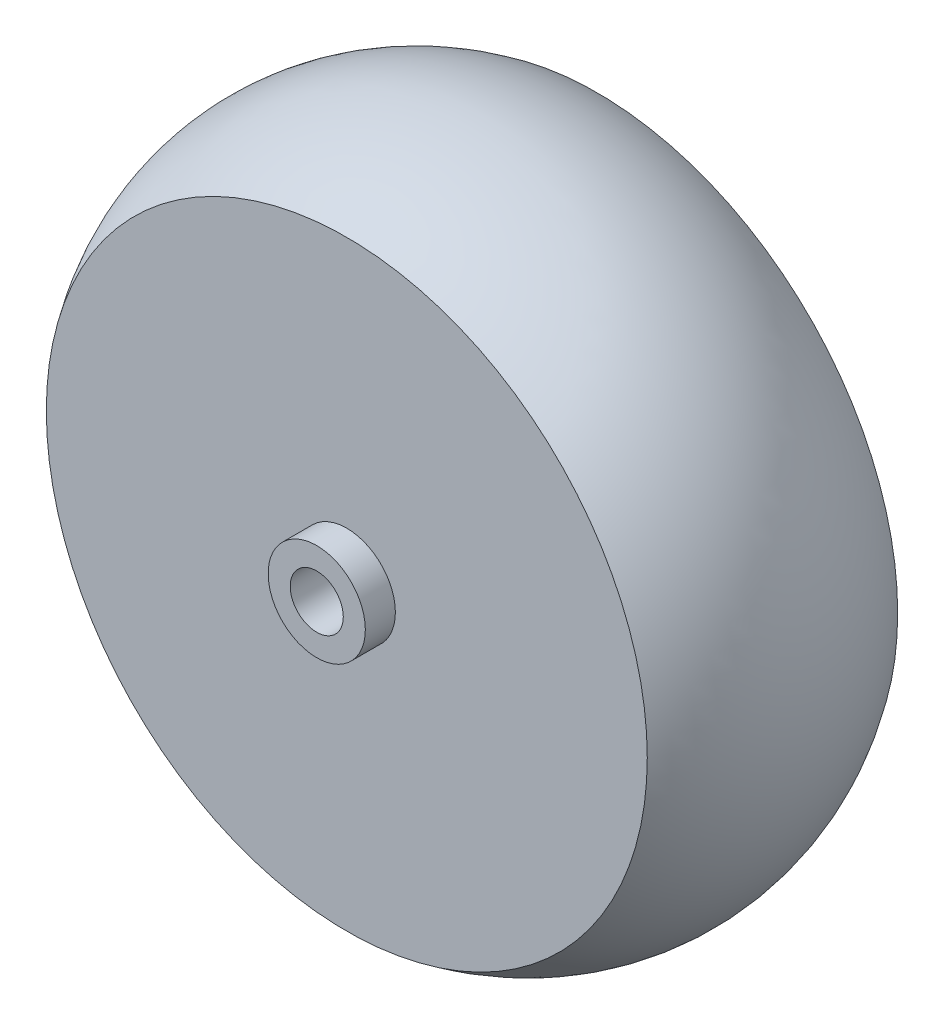
from build123d import *

# Parameters (mm, degrees)
CUT_EXTRUDE_1_DEPTH = 10
SKETCH_4_R          = 2.65
CUT_EXTRUDE_2_DEPTH = 5


with BuildPart() as part:
    # 草图2 → 旋转1 (revolve)
    with BuildSketch(Plane(origin=(0, 0, 0), x_dir=(1, 0, 0), z_dir=(0, 1, 0))):
        with BuildLine():
            Line((0, 0), (0, 28))
            Line((0, 28), (30, 28))
            ThreePointArc((30, 28), (34, 15.5), (30, 3))
            Line((30, 3), (4.85, 3))
            Line((4.85, 3), (4.85, 0))
            Line((4.85, 0), (0, 0))
        make_face()
    revolve(axis=Axis((0, 0, 0), (0, 0, -1)))

    # 草图3 → 切除-拉伸1 (cut)
    with BuildSketch(Plane.XY):
        with BuildLine():
            Line((1.989974874, 1.75), (-1.989974874, 1.75))
            ThreePointArc((-1.989974874, 1.75), (-2.65, 0), (-1.989974874, -1.75))
            Line((-1.989974874, -1.75), (1.989974874, -1.75))
            ThreePointArc((1.989974874, -1.75), (2.65, 0), (1.989974874, 1.75))
        make_face()
    extrude(amount=-CUT_EXTRUDE_1_DEPTH, mode=Mode.SUBTRACT)

    # 草图4 → 切除-拉伸2 (cut)
    with BuildSketch(Plane.XY):
        Circle(SKETCH_4_R)
    extrude(amount=-CUT_EXTRUDE_2_DEPTH, mode=Mode.SUBTRACT)


solid = part.part
